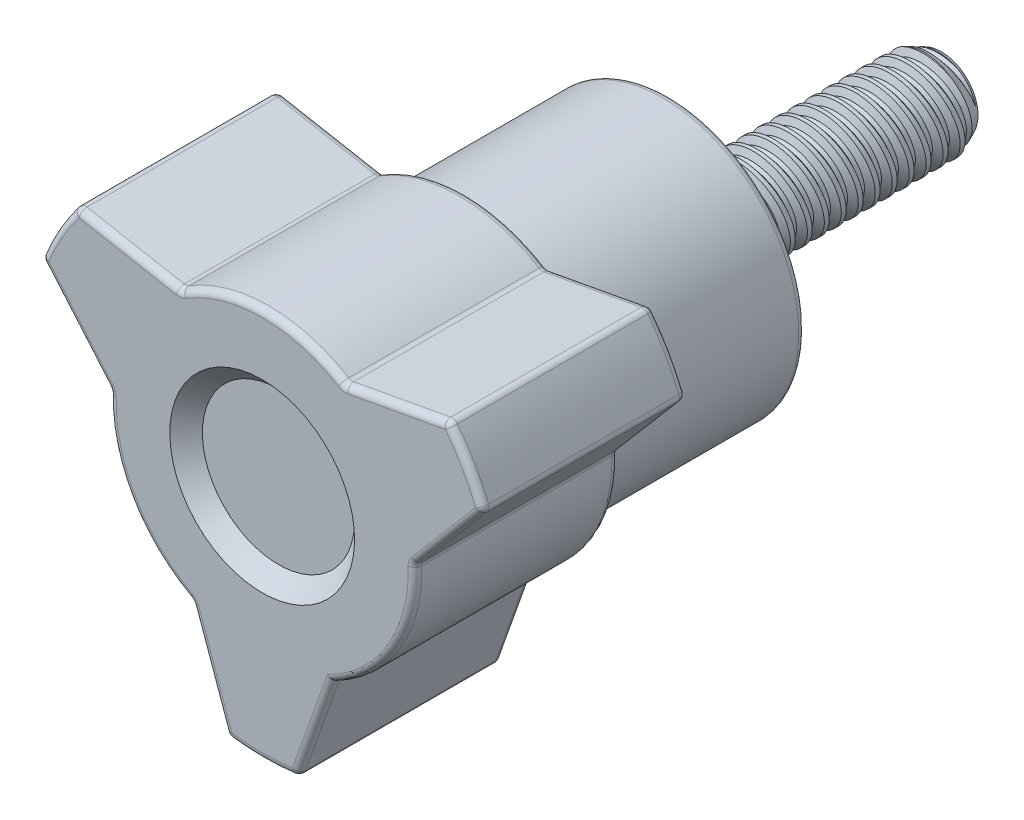
from build123d import *

# Parameters (mm, degrees)
SKETCH1_W           = 12.7
SKETCH1_H           = 2.0828
LPATTERN1_COUNT     = 16
LPATTERN1_PITCH     = 0.79375
LPATTERN1_COL_COUNT = 2
LPATTERN1_COL_PITCH = 0.79375
CUT_EXTRUDE1_START  = -31.75
CUT_EXTRUDE1_DEPTH  = 31.75
CIRPATTERN1_COUNT   = 3
FILLET4_R           = 0.3175


with BuildPart() as part:
    # Sketch1 → Revolve1 (revolve)
    with BuildSketch(Plane(origin=(0, 0, 0), x_dir=(0, 0, -1), z_dir=(1, 0, 0)), mode=Mode.PRIVATE) as revolve1_sk:
        with Locations((0, 1.0414)):
            Rectangle(SKETCH1_W, SKETCH1_H)
    revolve(revolve1_sk.sketch.rotate(Axis((0, 0, 8.5598), (0, 0, -1)), 180), axis=Axis((0, 0, 8.5598), (0, 0, -1)))

    # Sketch2 → Cut-Revolve1 (revolve, cut)
    with BuildSketch(Plane(origin=(0, 0, 0), x_dir=(0, 0, -1), z_dir=(1, 0, 0)), mode=Mode.PRIVATE) as cut_revolve1_sk:
        Polygon((-6.252535, 2.101372), (-5.570279, 2.231375), (-5.733523, 1.762909), (-5.928454, 1.725765), align=None)
    cut_revolve1 = revolve(cut_revolve1_sk.sketch.rotate(Axis((0, -0.162232, 6.35), (0, 0.18718091792156127, -0.9823254572523517)), 180), axis=Axis((0, -0.162232, 6.35), (0, 0.18718091792156127, -0.9823254572523517)), mode=Mode.SUBTRACT)

    # LPattern1: Cut-Revolve1 ×16
    with Locations(*[(0, 0, -i * LPATTERN1_PITCH) for i in range(1, LPATTERN1_COUNT)]):
        add(cut_revolve1, mode=Mode.SUBTRACT)

    # LPattern1 col: Cut-Revolve1 ×2
    with Locations(*[(0, 0, i * LPATTERN1_COL_PITCH) for i in range(1, LPATTERN1_COL_COUNT)]):
        add(cut_revolve1, mode=Mode.SUBTRACT)

    # Sketch5 → Revolve3 (revolve)
    with BuildSketch(Plane(origin=(0, 0, 0), x_dir=(0, 0, -1), z_dir=(1, 0, 0)), mode=Mode.PRIVATE) as revolve3_sk:
        Polygon((-6.35, 6.35), (-15.875, 6.35), (-15.875, 11.1125), (-25.4, 11.1125), (-25.4, 0), (-6.35, 0), align=None)
    revolve(revolve3_sk.sketch.rotate(Axis((0, 0, 6.35), (0, 0, -1)), 234.342988), axis=Axis((0, 0, 6.35), (0, 0, -1)))

    # Sketch6 → Cut-Extrude1 (cut)
    with BuildSketch(Plane.XY.offset(25.4).offset(CUT_EXTRUDE1_START)):
        with BuildLine():
            Line((8.6914, 6.924393), (3.835116, 6.027027))
            ThreePointArc((3.835116, 6.027027), (1.997197, 6.85889), (0, 7.14375))
            Line((0, 7.14375), (0, 14.2875))
            ThreePointArc((0, 14.2875), (12.373338, 7.14375), (12.373338, -7.14375))
            Line((12.373338, -7.14375), (6.186669, -3.571875))
            ThreePointArc((6.186669, -3.571875), (6.938571, -1.699821), (7.137116, 0.307795))
            Line((7.137116, 0.307795), (10.3424, 4.064777))
            ThreePointArc((10.3424, 4.064777), (9.623707, 5.55625), (8.6914, 6.924393))
        make_face()
    cut_extrude1 = extrude(amount=CUT_EXTRUDE1_DEPTH, mode=Mode.SUBTRACT)

    # CirPattern1: Cut-Extrude1 ×3 about axis
    cirpattern1_axis = Axis((0, 0, 0), (0, 0, 1))
    for i in range(1, CIRPATTERN1_COUNT):
        add(cut_extrude1.rotate(cirpattern1_axis, i * 360 / CIRPATTERN1_COUNT), mode=Mode.SUBTRACT)

    # Sketch10 → Cut-Revolve3 (revolve, cut)
    with BuildSketch(Plane(origin=(0, 0, 0), x_dir=(0, 0, -1), z_dir=(1, 0, 0)), mode=Mode.PRIVATE) as cut_revolve3_sk:
        Polygon((-25.4, 0), (-25.4, 4.318), (-24.638, 3.556), (-24.638, 0), align=None)
    revolve(cut_revolve3_sk.sketch.rotate(Axis((0, 0, -6.35), (0, 0, 1)), 125.657012), axis=Axis((0, 0, -6.35), (0, 0, 1)), mode=Mode.SUBTRACT)

    # Fillet4
    fillet4_edges = [part.edges().sort_by_distance(p)[0] for p in [
        (5.159509, 3.701617, 6.35),
        (9.623707, 5.55625, 25.4),
        (9.623707, 5.55625, 15.875),
        (10.3424, 4.064777, 20.6375),
        (6.186669, -3.571875, 15.875),
        (8.739758, 2.186286, 15.875),
        (8.739758, 2.186286, 25.4),
        (6.186669, -3.571875, 25.4),
        (7.137116, 0.307795, 20.6375),
        (6.263258, 6.47571, 15.875),
        (0, 7.14375, 15.875),
        (8.6914, 6.924393, 20.6375),
        (3.835116, 6.027027, 20.6375),
        (0, 7.14375, 25.4),
        (6.263258, 6.47571, 25.4),
        (-9.623707, 5.55625, 25.4),
        (-9.623707, 5.55625, 15.875),
        (-8.6914, 6.924393, 20.6375),
        (-6.263258, 6.47571, 15.875),
        (-6.263258, 6.47571, 25.4),
        (-3.835116, 6.027027, 20.6375),
        (0, -11.1125, 25.4),
        (0, -11.1125, 15.875),
        (-8.739758, 2.186286, 15.875),
        (-6.186669, -3.571875, 15.875),
        (-2.4765, -8.661996, 15.875),
        (-10.3424, 4.064777, 20.6375),
        (-1.651, -10.98917, 20.6375),
        (-7.137116, 0.307795, 20.6375),
        (-2.4765, -8.661996, 25.4),
        (-6.186669, -3.571875, 25.4),
        (-8.739758, 2.186286, 25.4),
        (-3.302, -6.334821, 20.6375),
        (2.4765, -8.661996, 15.875),
        (1.651, -10.98917, 20.6375),
        (2.4765, -8.661996, 25.4),
    ]]
    fillet(fillet4_edges, radius=FILLET4_R)

    # Sketch11 → Cut-Revolve4 (revolve, cut)
    with BuildSketch(Plane(origin=(0, 0, 0), x_dir=(0, 0, -1), z_dir=(1, 0, 0)), mode=Mode.PRIVATE) as cut_revolve4_sk:
        Polygon((5.55625, 2.0828), (6.35, 1.712668), (6.35, 2.0828), align=None)
    revolve(cut_revolve4_sk.sketch.rotate(Axis((0, 0, 0), (0, 0, -1)), 234.342988), axis=Axis((0, 0, 0), (0, 0, -1)), mode=Mode.SUBTRACT)


solid = part.part
